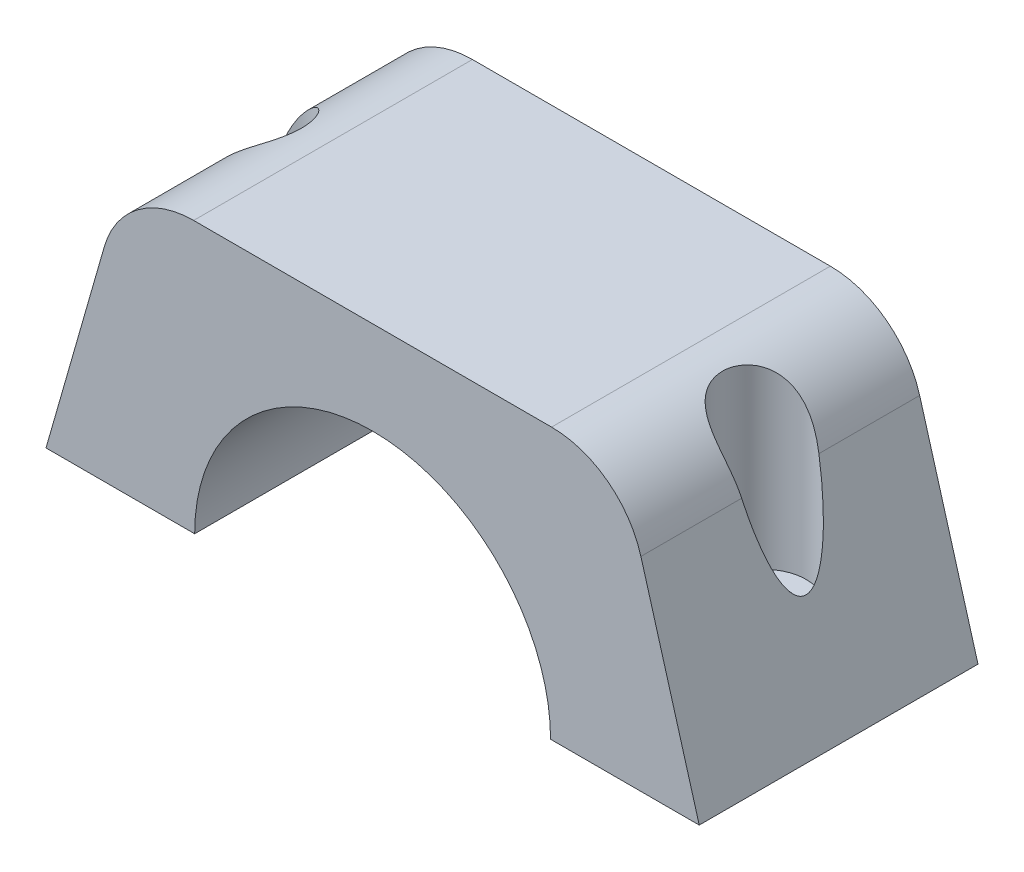
from build123d import *

# Parameters (mm, degrees)
BOSS_EXTRUDE1_DEPTH = 30
FILLET1_R           = 10
SKETCH2_R           = 2.5
CUT_EXTRUDE1_DEPTH  = 30.15
SKETCH3_R           = 4.5
CUT_EXTRUDE2_DEPTH  = 20


with BuildPart() as part:
    # Sketch1 → Boss-Extrude1 (new body)
    with BuildSketch(Plane.XY):
        with BuildLine():
            Line((-26.797076023, 29.15), (-35.15, 0))
            Line((-35.15, 0), (-19.15, 0))
            ThreePointArc((-19.15, 0), (0, 19.15), (19.15, 0))
            Line((19.15, 0), (35.15, 0))
            Line((35.15, 0), (26.797076023, 29.15))
            Line((26.797076023, 29.15), (-26.797076023, 29.15))
        make_face()
    extrude(amount=BOSS_EXTRUDE1_DEPTH)

    # Fillet1
    fillet1_edges = [part.edges().sort_by_distance(p)[0] for p in [
        (-26.797076023, 29.15, 15),
        (26.797076023, 29.15, 15),
    ]]
    fillet(fillet1_edges, radius=FILLET1_R)

    # Sketch2 → Cut-Extrude1 (cut, through all)
    with BuildSketch(Plane.XZ):
        with Locations((-27.15, 15)):
            Circle(SKETCH2_R)
        with Locations((27.15, 15)):
            Circle(SKETCH2_R)
    extrude(amount=-CUT_EXTRUDE1_DEPTH, mode=Mode.SUBTRACT)

    # Sketch3 → Cut-Extrude2 (cut)
    with BuildSketch(Plane(origin=(0, 29.15, 0), x_dir=(1, 0, 0), z_dir=(0, 1, 0))):
        with Locations((27.15, -15)):
            Circle(SKETCH3_R)
        with Locations((-27.15, -15)):
            Circle(SKETCH3_R)
    extrude(amount=-CUT_EXTRUDE2_DEPTH, mode=Mode.SUBTRACT)


solid = part.part
